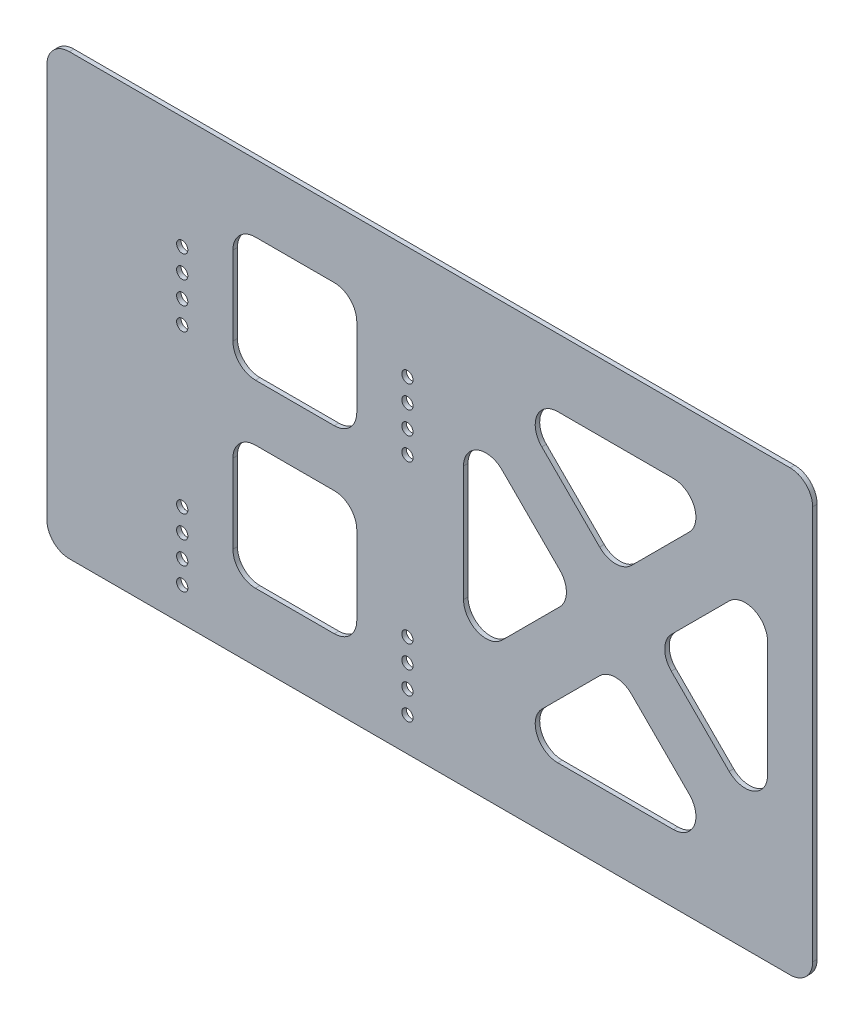
from build123d import *

# Parameters (mm, degrees)
SKETCH1_W           = 340
SKETCH1_H           = 195
BOSS_EXTRUDE1_DEPTH = 2
SKETCH2_R           = 2.5
CUT_EXTRUDE1_DEPTH  = 3
LPATTERN1_COUNT     = 2
LPATTERN1_PITCH     = 10
LPATTERN1_COL_COUNT = 3
LPATTERN1_COL_PITCH = 10
CUT_EXTRUDE2_DEPTH  = 3
SKETCH4_W           = 55
SKETCH4_H           = 55
CUT_EXTRUDE3_DEPTH  = 3
FILLET1_R           = 10
FILLET2_R           = 10


with BuildPart() as part:
    # Sketch1 → Boss-Extrude1 (new body)
    with BuildSketch(Plane.XY):
        with Locations((-439.9, -389.5)):
            Rectangle(SKETCH1_W, SKETCH1_H)
    extrude(amount=BOSS_EXTRUDE1_DEPTH)

    # Sketch2 → Cut-Extrude1 (cut, through all)
    with BuildSketch(Plane.XY.offset(2)):
        with Locations((-449.8, -362)):
            Circle(SKETCH2_R)
        with Locations((-449.8, -462)):
            Circle(SKETCH2_R)
        with Locations((-549.8, -462)):
            Circle(SKETCH2_R)
        with Locations((-549.8, -362)):
            Circle(SKETCH2_R)
    cut_extrude1 = extrude(amount=-CUT_EXTRUDE1_DEPTH, mode=Mode.SUBTRACT)

    # LPattern1: Cut-Extrude1 ×2
    with Locations(*[(0, -i * LPATTERN1_PITCH, 0) for i in range(1, LPATTERN1_COUNT)]):
        add(cut_extrude1, mode=Mode.SUBTRACT)

    # LPattern1 col: Cut-Extrude1 ×3
    with Locations(*[(0, i * LPATTERN1_COL_PITCH, 0) for i in range(1, LPATTERN1_COL_COUNT)]):
        add(cut_extrude1, mode=Mode.SUBTRACT)

    # Sketch3 → Cut-Extrude2 (cut, through all)
    with BuildSketch(Plane.XY.offset(2)):
        Polygon((-307.57766953, -457), (-357.4, -407.17766953), (-407.22233047, -457), align=None)
        Polygon((-289.9, -439.32233047), (-339.72233047, -389.5), (-289.9, -339.67766953), align=None)
        Polygon((-375.07766953, -389.5), (-424.9, -439.32233047), (-424.9, -339.67766953), align=None)
        Polygon((-357.4, -371.82233047), (-307.57766953, -322), (-407.22233047, -322), align=None)
    extrude(amount=-CUT_EXTRUDE2_DEPTH, mode=Mode.SUBTRACT)

    # Sketch4 → Cut-Extrude3 (cut, through all)
    with BuildSketch(Plane.XY.offset(2)):
        with Locations((-499.8, -429.5)):
            Rectangle(SKETCH4_W, SKETCH4_H)
        with Locations((-499.8, -349.5)):
            Rectangle(SKETCH4_W, SKETCH4_H)
    extrude(amount=-CUT_EXTRUDE3_DEPTH, mode=Mode.SUBTRACT)

    # Fillet1
    fillet1_edges = [part.edges().sort_by_distance(p)[0] for p in [
        (-289.9, -339.67766953, 1),
        (-289.9, -439.32233047, 1),
        (-339.72233047, -389.5, 1),
        (-424.9, -339.67766953, 1),
        (-375.07766953, -389.5, 1),
        (-424.9, -439.32233047, 1),
        (-357.4, -371.82233047, 1),
        (-407.22233047, -322, 1),
        (-307.57766953, -322, 1),
        (-307.57766953, -457, 1),
        (-407.22233047, -457, 1),
        (-357.4, -407.17766953, 1),
        (-472.3, -402, 1),
        (-472.3, -457, 1),
        (-527.3, -457, 1),
        (-527.3, -402, 1),
        (-472.3, -322, 1),
        (-472.3, -377, 1),
        (-527.3, -377, 1),
        (-527.3, -322, 1),
    ]]
    fillet(fillet1_edges, radius=FILLET1_R)

    # Fillet2
    fillet2_edges = [part.edges().sort_by_distance(p)[0] for p in [
        (-269.9, -487, 1),
        (-609.9, -487, 1),
        (-609.9, -292, 1),
        (-269.9, -292, 1),
    ]]
    fillet(fillet2_edges, radius=FILLET2_R)


solid = part.part
